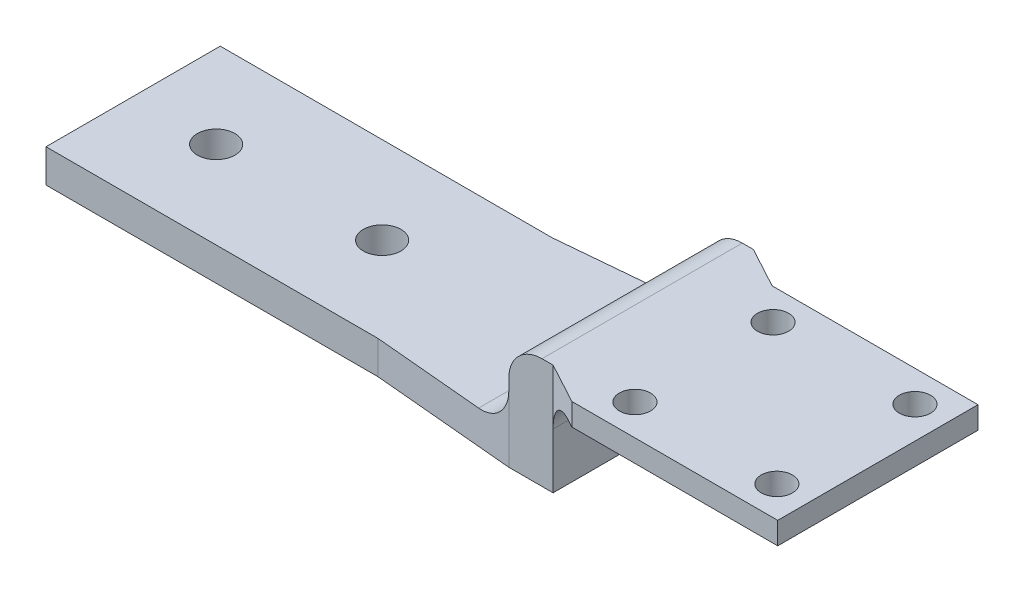
from build123d import *

# Parameters (mm, degrees)
BODY_DEPTH                           = 38.1
F_13_64_0_20313_DIAMETER_HOLE1_D     = 5.159502
F_13_64_0_20313_DIAMETER_HOLE1_DEPTH = 3.556
F_13_64_0_20313_DIAMETER_HOLE1_TIP   = 1.550070783
CHAMFER1_SIZE                        = 0.635
CHAMFER1_SIZE2                       = 0.366617421
REACHER_DEPTH                        = 3.81
SKETCH13_W                           = 5.08
SKETCH13_H                           = 22.987
BOSS_EXTRUDE4_DEPTH                  = 8.89
SKETCH11_R                           = 1.7907
BOSS_EXTRUDE3_DEPTH                  = 2.54
FILLET1_R                            = 3.81


with BuildPart() as part:
    # Profile → Body (new body)
    with BuildSketch(Plane(origin=(0, 0, 0), x_dir=(0, 0, -1), z_dir=(1, 0, 0))):
        Polygon((20, -1.905), (20, 1.905), (0, 1.905), (0, -1.905), (4.92, -1.905), (10, -1.905), (15.08, -1.905), align=None)
    extrude(amount=BODY_DEPTH)

    # 13_64 _0.20313_ Diameter Hole1
    with Locations(Plane(origin=(0, -1.905, 0), x_dir=(-1, 0, 0), z_dir=(0, -1, 0))):
        with Locations((-28.575, 10), (-9.525, 10)):
            Hole(F_13_64_0_20313_DIAMETER_HOLE1_D / 2, depth=F_13_64_0_20313_DIAMETER_HOLE1_DEPTH)
            with Locations((0, 0, -(F_13_64_0_20313_DIAMETER_HOLE1_DEPTH + F_13_64_0_20313_DIAMETER_HOLE1_TIP / 2))):  # 118° drill point
                Cone(0, F_13_64_0_20313_DIAMETER_HOLE1_D / 2, F_13_64_0_20313_DIAMETER_HOLE1_TIP, mode=Mode.SUBTRACT)

    # Chamfer1
    chamfer1_edges = [part.edges().sort_by_distance(p)[0] for p in [
        (6.945249, -1.905, -10),
        (25.995249, -1.905, -10),
    ]]
    chamfer1_side = [part.faces().sort_by_distance(p)[0] for p in [
        (19.05, -1.905, -10),
    ]]
    chamfer(chamfer1_edges, length=CHAMFER1_SIZE, length2=CHAMFER1_SIZE2, reference=chamfer1_side[0])

    # Sketch9 → Reacher (add)
    with BuildSketch(Plane(origin=(0, -1.905, 0), x_dir=(1, 0, 0), z_dir=(0, 1, 0))):
        Polygon((54.61, 21.4935), (38.1, 20), (38.1, 0), (54.61, -1.4935), (59.69, -1.4935), (59.69, 21.4935), align=None)
    extrude(amount=REACHER_DEPTH)

    # Sketch13 → Boss-Extrude4 (add)
    with BuildSketch(Plane(origin=(0, 1.905, 0), x_dir=(1, 0, 0), z_dir=(0, 1, 0))):
        with Locations((57.15, 10)):
            Rectangle(SKETCH13_W, SKETCH13_H)
    extrude(amount=BOSS_EXTRUDE4_DEPTH)

    # Sketch11 → Boss-Extrude3 (add)
    with BuildSketch(Plane(origin=(0, 10.795, 0), x_dir=(1, 0, 0), z_dir=(0, 1, 0))):
        Polygon((64.389, -4.0335), (88.011, -4.0335), (88.011, 18.9535), (64.389, 18.9535), (59.69, 21.4935), (59.69, -1.4935), align=None)
        with Locations((68.056282873, 15.3848)):
            Circle(SKETCH11_R, mode=Mode.SUBTRACT)
        with Locations((84.343717127, 15.3848)):
            Circle(SKETCH11_R, mode=Mode.SUBTRACT)
        with Locations((84.343717127, -0.4648)):
            Circle(SKETCH11_R, mode=Mode.SUBTRACT)
        with Locations((68.056282873, -0.4648)):
            Circle(SKETCH11_R, mode=Mode.SUBTRACT)
    extrude(amount=-BOSS_EXTRUDE3_DEPTH)

    # Fillet1
    fillet1_edges = [part.edges().sort_by_distance(p)[0] for p in [
        (54.61, 1.905, -10),
        (59.69, 8.255, -10),
        (54.61, 10.795, -10),
    ]]
    fillet(fillet1_edges, radius=FILLET1_R)


solid = part.part
